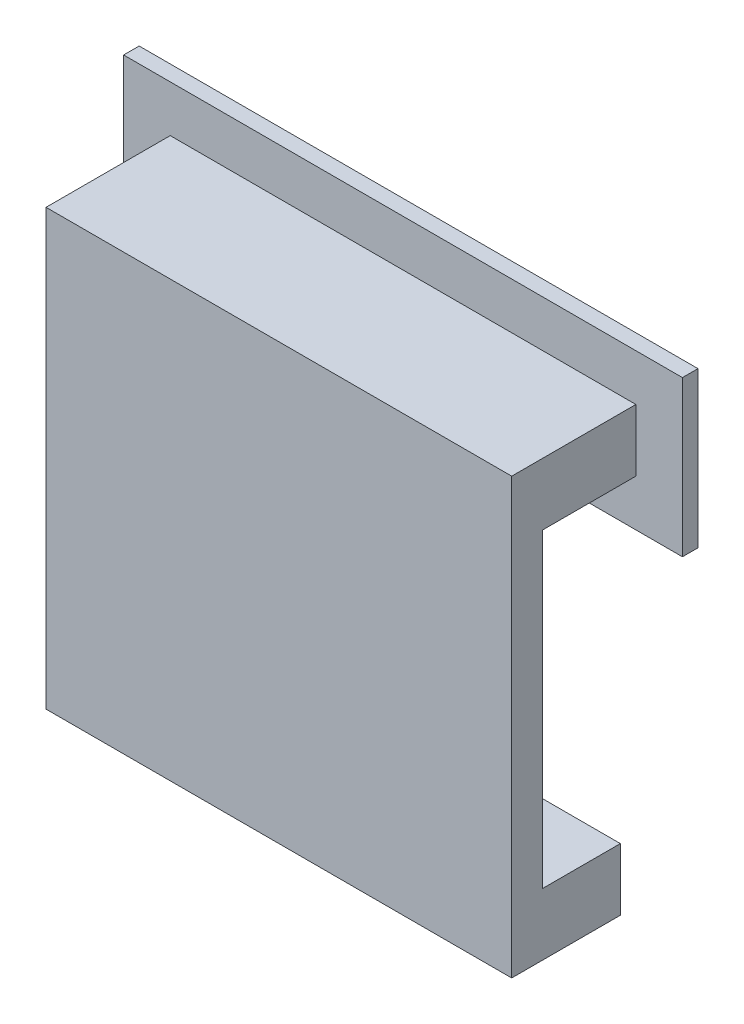
from build123d import *

# Parameters (mm, degrees)
SKETCH1_W           = 38.1
SKETCH1_H           = 5.08
BOSS_EXTRUDE1_DEPTH = 2.54
SKETCH2_W           = 38.1
SKETCH2_H           = 2.54
BOSS_EXTRUDE2_DEPTH = 30.48
SKETCH3_W           = 38.1
SKETCH3_H           = 5.08
BOSS_EXTRUDE3_DEPTH = 7.62
SKETCH4_W           = 38.1
SKETCH4_H           = 5.08
BOSS_EXTRUDE4_DEPTH = 6.35
SKETCH5_W           = 45.72
SKETCH5_H           = 12.7
BOSS_EXTRUDE5_DEPTH = 1.27


with BuildPart() as part:
    # Sketch1 → Boss-Extrude1 (new body)
    with BuildSketch(Plane.XY):
        Rectangle(SKETCH1_W, SKETCH1_H)
    extrude(amount=BOSS_EXTRUDE1_DEPTH)

    # Sketch2 → Boss-Extrude2 (add)
    with BuildSketch(Plane(origin=(0, 2.54, 0), x_dir=(1, 0, 0), z_dir=(0, 1, 0))):
        with Locations((0, -1.27)):
            Rectangle(SKETCH2_W, SKETCH2_H)
    extrude(amount=BOSS_EXTRUDE2_DEPTH)

    # Sketch3 → Boss-Extrude3 (add)
    with BuildSketch(Plane(origin=(0, 0, 0), x_dir=(-1, 0, 0), z_dir=(0, 0, -1))):
        with Locations((0, 30.48)):
            Rectangle(SKETCH3_W, SKETCH3_H)
    extrude(amount=BOSS_EXTRUDE3_DEPTH)

    # Sketch4 → Boss-Extrude4 (add)
    with BuildSketch(Plane(origin=(0, 0, 0), x_dir=(-1, 0, 0), z_dir=(0, 0, -1))):
        Rectangle(SKETCH4_W, SKETCH4_H)
    extrude(amount=BOSS_EXTRUDE4_DEPTH)

    # Sketch5 → Boss-Extrude5 (add)
    with BuildSketch(Plane(origin=(0, 0, -7.62), x_dir=(-1, 0, 0), z_dir=(0, 0, -1))):
        with Locations((0, 30.48)):
            Rectangle(SKETCH5_W, SKETCH5_H)
    extrude(amount=BOSS_EXTRUDE5_DEPTH)


solid = part.part
